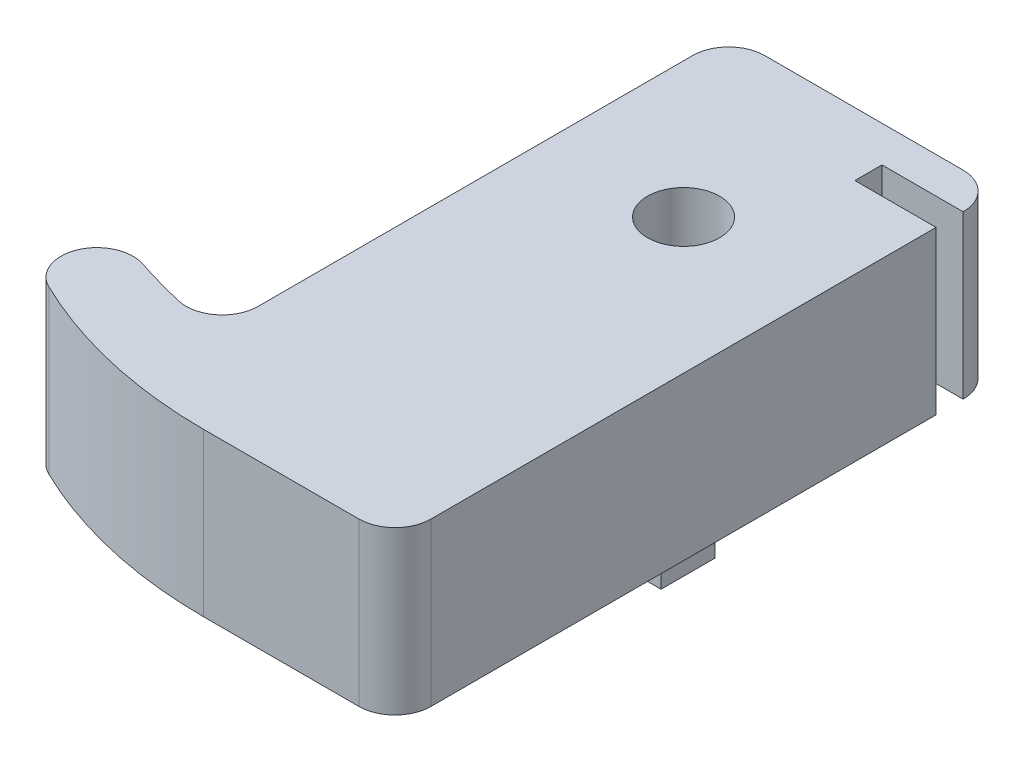
from build123d import *

# Parameters (mm, degrees)
SKETCH_1_R          = 2
EXTRUDE_1_DEPTH     = 9
SKETCH_3_W          = 2.5
SKETCH_3_H          = 3
EXTRUDE_2_DEPTH     = 1.5
CUT_EXTRUDE_1_REACH = 11
SKETCH_5_W          = 13
SKETCH_5_H          = 1.5
SKETCH_7_W          = 8.5
SKETCH_7_H          = 1.5
EXTRUDE_3_DEPTH     = 4
SKETCH_9_W          = 49.545975543
SKETCH_9_H          = 42.208236046
CUT_EXTRUDE_3_DEPTH = 11.5


with BuildPart() as part:
    # 草图1 → 凸台-拉伸1 (new body)
    with BuildSketch(Plane(origin=(0, 0, 0), x_dir=(1, 0, 0), z_dir=(0, 1, 0))):
        with BuildLine():
            Line((-2.382835885, 33.5), (8.617164115, 33.5))
            ThreePointArc((8.617164115, 33.5), (10.031377677, 32.914213562), (10.617164115, 31.5))
            Line((10.617164115, 31.5), (10.617164115, 2))
            ThreePointArc((10.617164115, 2), (10.031377677, 0.585786438), (8.617164115, 0))
            Line((8.617164115, 0), (0, 0))
            ThreePointArc((0, 0), (-5.710600422, 0.647655185), (-11.131122415, 2.557722132))
            ThreePointArc((-11.131122415, 2.557722132), (-12.111898361, 5.107720531), (-9.633282348, 6.257014206))
            ThreePointArc((-9.633282348, 6.257014206), (-8.243555708, 5.833986106), (-6.836394497, 5.473167269))
            ThreePointArc((-6.836394497, 5.473167269), (-5.139275919, 5.854675685), (-4.382835885, 7.421059613))
            Line((-4.382835885, 7.421059613), (-4.382835885, 31.5))
            ThreePointArc((-4.382835885, 31.5), (-3.797049447, 32.914213562), (-2.382835885, 33.5))
        make_face()
        with Locations((3.117164115, 23.5)):
            Circle(SKETCH_1_R, mode=Mode.SUBTRACT)
    extrude(amount=EXTRUDE_1_DEPTH)

    # 草图3 → 凸台-拉伸2 (add)
    with BuildSketch(Plane(origin=(0, 9, 0), x_dir=(1, 0, 0), z_dir=(0, 1, 0))):
        with Locations((-2.382835885, 17)):
            Rectangle(SKETCH_3_W, SKETCH_3_H)
        with Locations((8.617164115, 17)):
            Rectangle(SKETCH_3_W, SKETCH_3_H)
    extrude(amount=EXTRUDE_2_DEPTH)

    # 草图5 → 切除-拉伸1 (cut, up to next)
    with BuildSketch(Plane(origin=(0, 9, 0), x_dir=(1, 0, 0), z_dir=(0, 1, 0)), mode=Mode.PRIVATE) as cut_extrude_1_sk1:
        with Locations((4.117164115, 30.75)):
            Rectangle(SKETCH_5_W, SKETCH_5_H)
    cut_extrude_1_tool1 = extrude(cut_extrude_1_sk1.sketch, amount=-CUT_EXTRUDE_1_REACH, mode=Mode.PRIVATE) & part.part
    add(cut_extrude_1_tool1.solids().sort_by_distance((4.117164, 9, -30.75))[0], mode=Mode.SUBTRACT)

    # 草图7 → 凸台-拉伸3 (add)
    with BuildSketch(Plane.XZ):
        with Locations((1.867164115, -30.75)):
            Rectangle(SKETCH_7_W, SKETCH_7_H)
    extrude(amount=-EXTRUDE_3_DEPTH)

    # 镜向8: part across plane


with BuildPart() as part_1:
    add(part.part)
    add(part.part.mirror(Plane(origin=(0, 0, -25.5), x_dir=(0, 0, 1), z_dir=(0, -1, 0))))

    # 草图9 → 切除-拉伸3 (cut, through all)
    with BuildSketch(Plane(origin=(0, 0, 0), x_dir=(1, 0, 0), z_dir=(0, 1, 0))):
        with Locations((0.218507418, 15.905835279)):
            Rectangle(SKETCH_9_W, SKETCH_9_H)
    extrude(amount=CUT_EXTRUDE_3_DEPTH, mode=Mode.SUBTRACT)


solid = part_1.part
